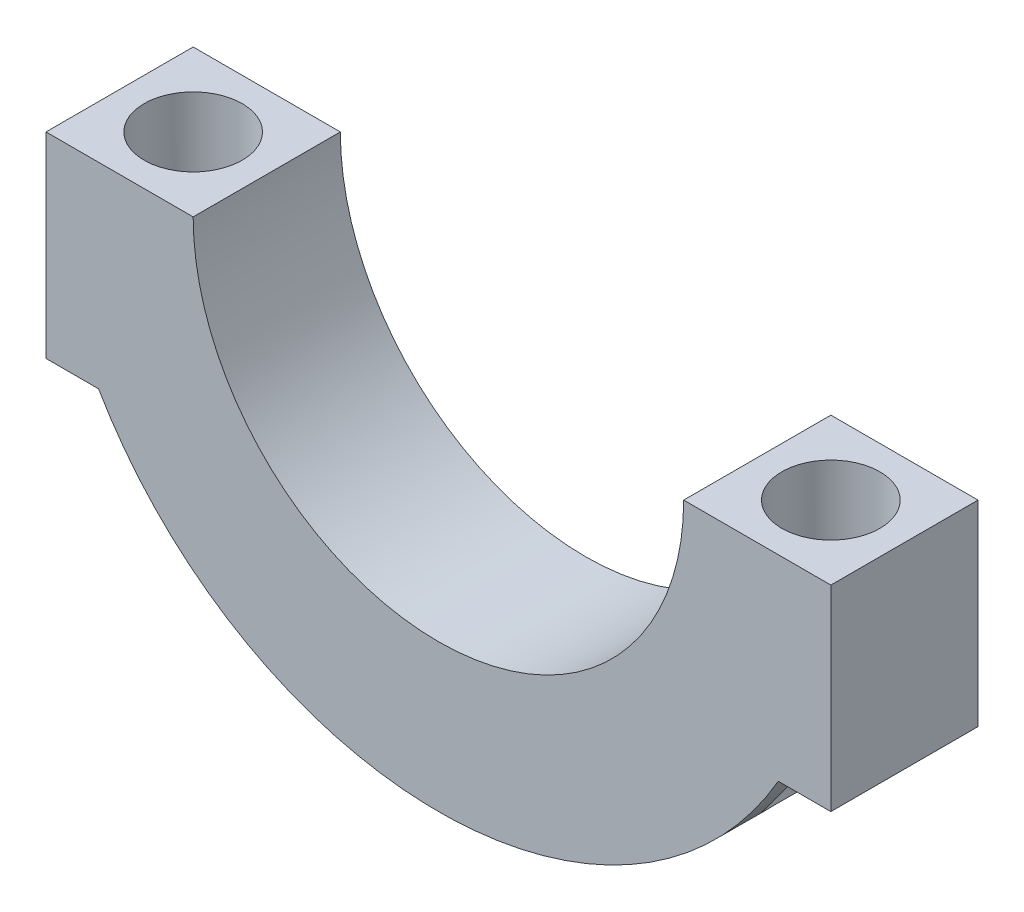
from build123d import *

# Parameters (mm, degrees)
BOSS_EXTRUDE4_DEPTH = 15
SKETCH5_R           = 5
CUT_EXTRUDE1_DEPTH  = 41


with BuildPart() as part:
    # Sketch2 → Boss-Extrude4 (new body)
    with BuildSketch(Plane.XY):
        with BuildLine():
            Line((-40, 0), (-25, 0))
            ThreePointArc((-25, 0), (0, -25), (25, 0))
            Line((25, 0), (40, 0))
            Line((40, 0), (40, -20))
            Line((40, -20), (34.641016151, -20))
            ThreePointArc((34.641016151, -20), (0, -40), (-34.641016151, -20))
            Line((-34.641016151, -20), (-40, -20))
            Line((-40, -20), (-40, 0))
        make_face()
    extrude(amount=BOSS_EXTRUDE4_DEPTH)

    # Sketch5 → Cut-Extrude1 (cut, through all)
    with BuildSketch(Plane(origin=(0, 0, 0), x_dir=(1, 0, 0), z_dir=(0, 1, 0))):
        with Locations((-32.5, -7.5)):
            Circle(SKETCH5_R)
        with Locations((32.5, -7.5)):
            Circle(SKETCH5_R)
    extrude(amount=-CUT_EXTRUDE1_DEPTH, mode=Mode.SUBTRACT)


solid = part.part
